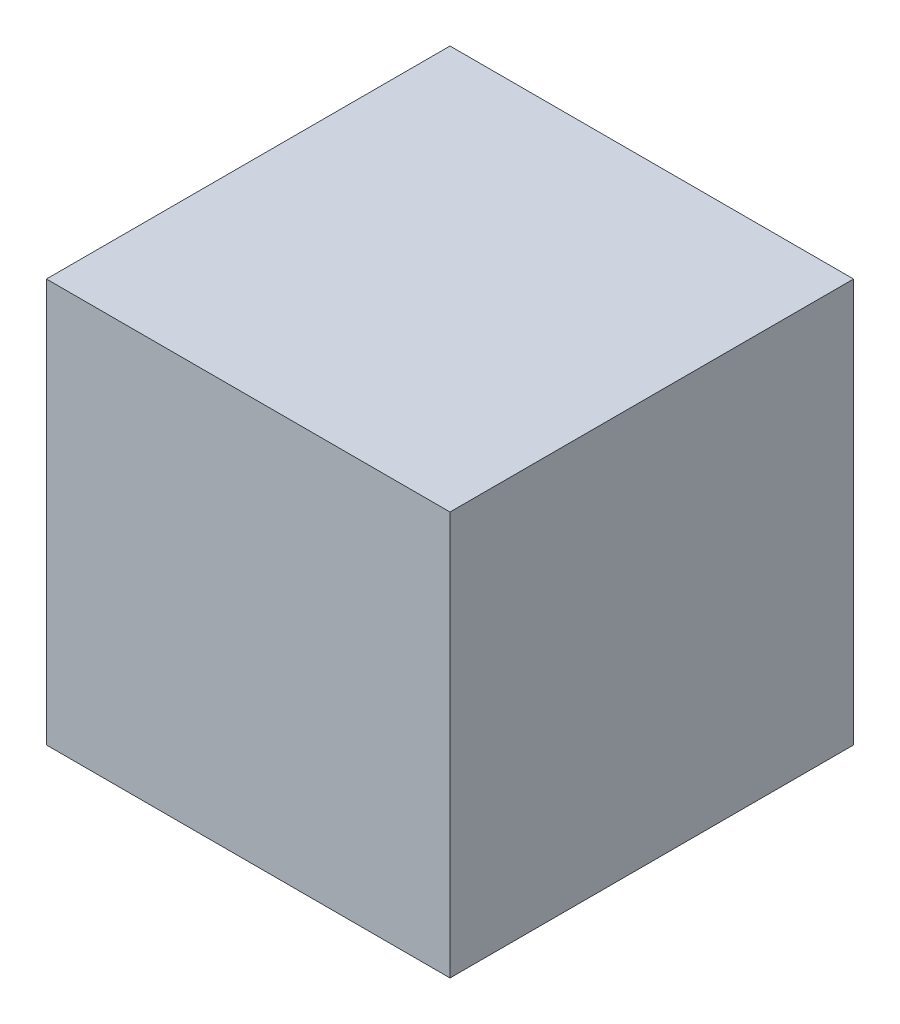
from build123d import *

# Parameters (mm, degrees)
SKETCH1_W           = 10
SKETCH1_H           = 10
BOSS_EXTRUDE1_DEPTH = 10


with BuildPart() as part:
    # Sketch1 → Boss-Extrude1 (new body)
    with BuildSketch(Plane.XY):
        with Locations((-48.367658053, 9.623435722)):
            Rectangle(SKETCH1_W, SKETCH1_H)
    extrude(amount=BOSS_EXTRUDE1_DEPTH)


solid = part.part
